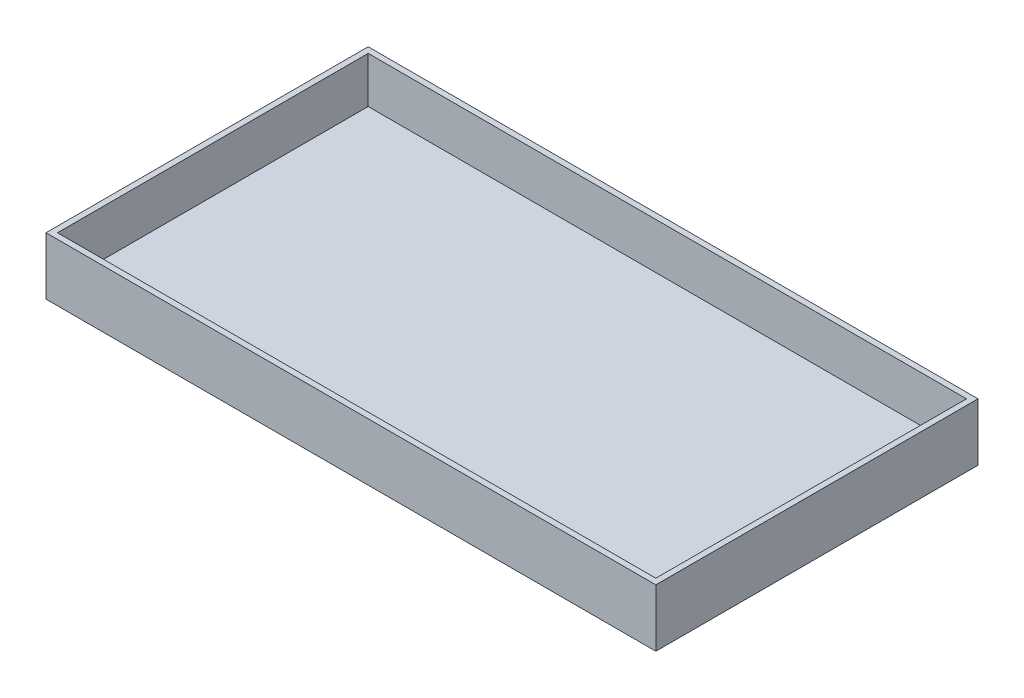
from build123d import *

# Parameters (mm, degrees)
SKETCH1_W           = 106
SKETCH1_H           = 56
SKETCH1_W_2         = 104
SKETCH1_H_2         = 54
BOSS_EXTRUDE1_DEPTH = 10
SKETCH2_W           = 106
SKETCH2_H           = 56
BOSS_EXTRUDE2_DEPTH = 2


with BuildPart() as part:
    # Sketch1 → Boss-Extrude1 (new body)
    with BuildSketch(Plane(origin=(0, 0, 0), x_dir=(1, 0, 0), z_dir=(0, 1, 0))):
        Rectangle(SKETCH1_W, SKETCH1_H)
        Rectangle(SKETCH1_W_2, SKETCH1_H_2, mode=Mode.SUBTRACT)
    extrude(amount=BOSS_EXTRUDE1_DEPTH)

    # Sketch2 → Boss-Extrude2 (add)
    with BuildSketch(Plane(origin=(0, 0, 0), x_dir=(1, 0, 0), z_dir=(0, 1, 0))):
        Rectangle(SKETCH2_W, SKETCH2_H)
    extrude(amount=BOSS_EXTRUDE2_DEPTH)


solid = part.part
